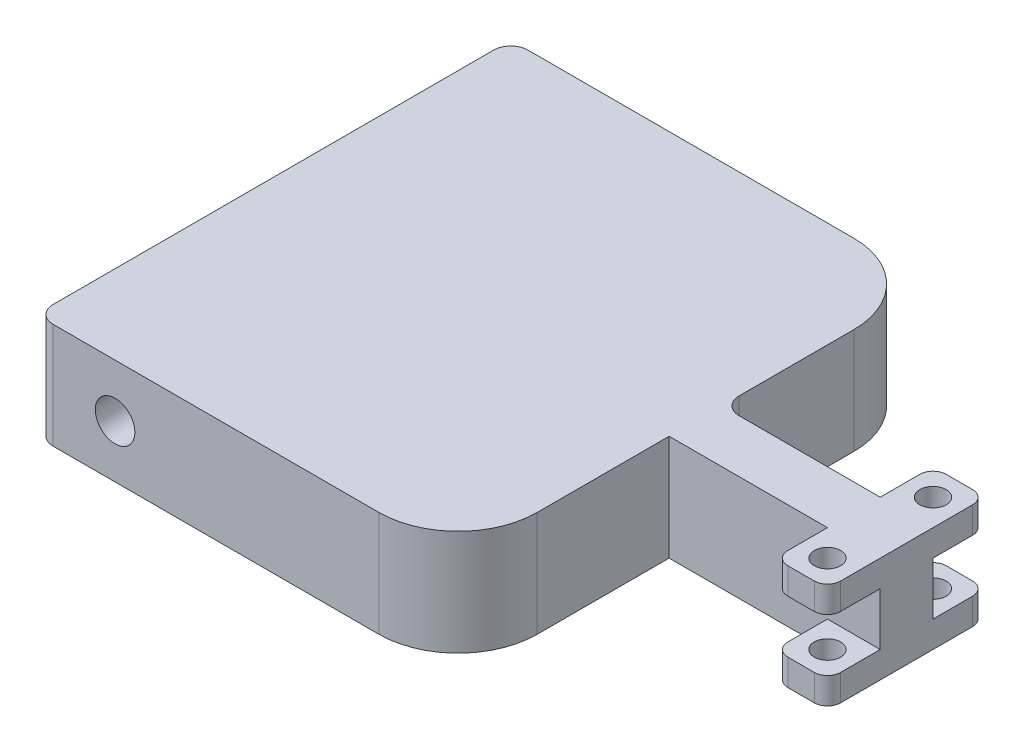
from build123d import *

# Parameters (mm, degrees)
BOSS_EXTRUDE1_DEPTH     = 50.8
CUT_EXTRUDE1_DEPTH      = 25.4
CUT_EXTRUDE2_START      = -102.6
SKETCH3_R               = 12.7
CUT_EXTRUDE2_DEPTH      = 103.6
SKETCH4_R               = 19.05
CUT_EXTRUDE3_DEPTH      = 1
CUT_EXTRUDE3_DEPTH_BACK = 458.2
FILLET1_R               = 16.51


with BuildPart() as part:
    # Sketch1 → Boss-Extrude1 (new body, symmetric)
    with BuildSketch(Plane(origin=(0, 0, 0), x_dir=(1, 0, 0), z_dir=(0, 1, 0))):
        with BuildLine():
            Line((76.2, -25.4), (-76.2, -25.4))
            Line((-76.2, -25.4), (-76.2, -152.4))
            ThreePointArc((-76.2, -152.4), (-98.518463274, -206.281536726), (-152.4, -228.6))
            Line((-152.4, -228.6), (-482.6, -228.6))
            Line((-482.6, -228.6), (-482.6, 228.6))
            Line((-482.6, 228.6), (-152.4, 228.6))
            ThreePointArc((-152.4, 228.6), (-98.518463274, 206.281536726), (-76.2, 152.4))
            Line((-76.2, 152.4), (-76.2, 25.4))
            Line((-76.2, 25.4), (76.2, 25.4))
            Line((76.2, 25.4), (76.2, 63.5))
            ThreePointArc((76.2, 63.5), (79.919743879, 72.480256121), (88.9, 76.2))
            Line((88.9, 76.2), (114.3, 76.2))
            ThreePointArc((114.3, 76.2), (123.280256121, 72.480256121), (127, 63.5))
            Line((127, 63.5), (127, -63.5))
            ThreePointArc((127, -63.5), (123.280256121, -72.480256121), (114.3, -76.2))
            Line((114.3, -76.2), (88.9, -76.2))
            ThreePointArc((88.9, -76.2), (79.919743879, -72.480256121), (76.2, -63.5))
            Line((76.2, -63.5), (76.2, -25.4))
        make_face()
    extrude(amount=BOSS_EXTRUDE1_DEPTH, both=True)

    # Sketch2 → Cut-Extrude1 (cut, symmetric)
    with BuildSketch(Plane(origin=(0, 0, 0), x_dir=(1, 0, 0), z_dir=(0, 1, 0))):
        with BuildLine():
            Line((127, -63.5), (127, -25.4))
            Line((127, -25.4), (76.2, -25.4))
            Line((76.2, -25.4), (76.2, -63.5))
            ThreePointArc((76.2, -63.5), (79.919743879, -72.480256121), (88.9, -76.2))
            Line((88.9, -76.2), (114.3, -76.2))
            ThreePointArc((114.3, -76.2), (123.280256121, -72.480256121), (127, -63.5))
        make_face()
    cut_extrude1 = extrude(amount=CUT_EXTRUDE1_DEPTH, both=True, mode=Mode.SUBTRACT)

    # Sketch3 → Cut-Extrude2 (cut)
    with BuildSketch(Plane(origin=(0, 50.8, 0), x_dir=(1, 0, 0), z_dir=(0, 1, 0)).offset(CUT_EXTRUDE2_START)):
        with Locations((101.6, -50.8)):
            Circle(SKETCH3_R)
    cut_extrude2 = extrude(amount=CUT_EXTRUDE2_DEPTH, mode=Mode.SUBTRACT)

    # Mirror1: Cut-Extrude1, Cut-Extrude2 across plane
    add(cut_extrude1.mirror(Plane.XY), mode=Mode.SUBTRACT)
    add(cut_extrude2.mirror(Plane.XY), mode=Mode.SUBTRACT)

    # Sketch4 → Cut-Extrude3 (cut, two sides)
    with BuildSketch(Plane.XY.offset(228.6)) as cut_extrude3_sk:
        with Locations((-406.4, 0)):
            Circle(SKETCH4_R)
    extrude(amount=CUT_EXTRUDE3_DEPTH, mode=Mode.SUBTRACT)
    extrude(cut_extrude3_sk.sketch, amount=-CUT_EXTRUDE3_DEPTH_BACK, mode=Mode.SUBTRACT)

    # Fillet1
    fillet1_edges = [part.edges().sort_by_distance(p)[0] for p in [
        (-482.6, 0, -228.6),
        (-76.2, 0, -25.4),
        (-482.6, 0, 228.6),
    ]]
    fillet(fillet1_edges, radius=FILLET1_R)


solid = part.part
